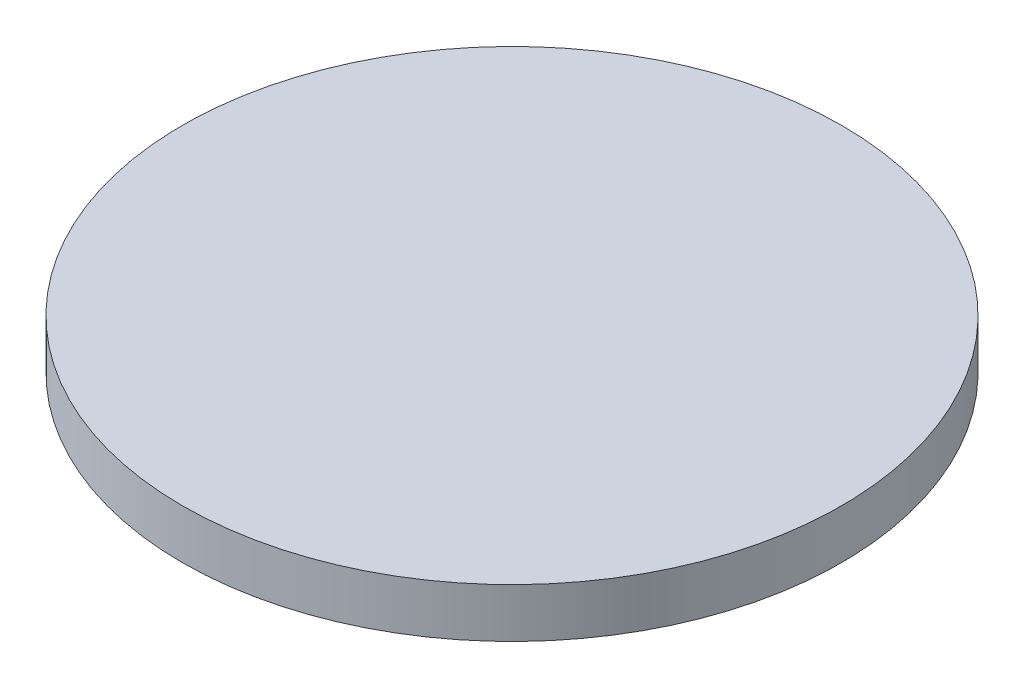
from build123d import *

# Parameters (mm, degrees)
SKETCH1_R           = 20.32
BOSS_EXTRUDE1_DEPTH = 3.03784


with BuildPart() as part:
    # Sketch1 → Boss-Extrude1 (new body)
    with BuildSketch(Plane(origin=(0, 0, 0), x_dir=(1, 0, 0), z_dir=(0, 1, 0))):
        Circle(SKETCH1_R)
    extrude(amount=BOSS_EXTRUDE1_DEPTH)


solid = part.part
